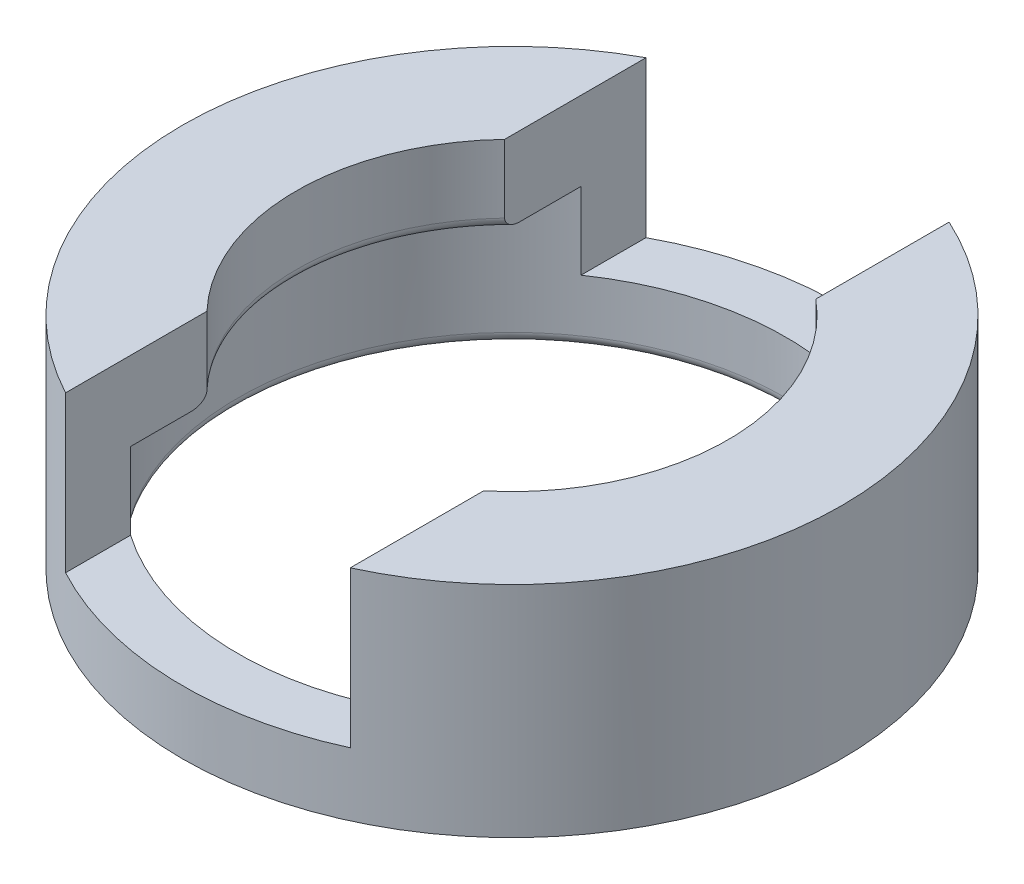
from build123d import *

# Parameters (mm, degrees)
SKETCH1_R               = 30.55
BOSS_EXTRUDE1_DEPTH     = 20.32
SKETCH2_R               = 25.404
CUT_EXTRUDE1_DEPTH      = 13
SKETCH3_R               = 20
CUT_EXTRUDE2_DEPTH      = 21.32
FILLET1_R               = 1
FILLET2_R               = 1
SKETCH4_W               = 27.244453354
SKETCH4_H               = 24.319072788
CUT_EXTRUDE3_DEPTH      = 31.55
CUT_EXTRUDE3_DEPTH_BACK = 31.55


with BuildPart() as part:
    # Sketch1 → Boss-Extrude1 (new body)
    with BuildSketch(Plane(origin=(0, 0, 0), x_dir=(1, 0, 0), z_dir=(0, 1, 0))):
        Circle(SKETCH1_R)
    extrude(amount=BOSS_EXTRUDE1_DEPTH)

    # Sketch2 → Cut-Extrude1 (cut)
    with BuildSketch(Plane.XZ):
        Circle(SKETCH2_R)
    extrude(amount=-CUT_EXTRUDE1_DEPTH, mode=Mode.SUBTRACT)

    # Sketch3 → Cut-Extrude2 (cut, through all)
    with BuildSketch(Plane(origin=(0, 20.32, 0), x_dir=(1, 0, 0), z_dir=(0, 1, 0))):
        Circle(SKETCH3_R)
    extrude(amount=-CUT_EXTRUDE2_DEPTH, mode=Mode.SUBTRACT)

    # Fillet1
    fillet1_edges = [part.edges().sort_by_distance(p)[0] for p in [
        (-25.404, 0, 0),
    ]]
    fillet(fillet1_edges, radius=FILLET1_R)

    # Fillet2
    fillet2_edges = [part.edges().sort_by_distance(p)[0] for p in [
        (-20, 13, 0),
    ]]
    fillet(fillet2_edges, radius=FILLET2_R)

    # Sketch4 → Cut-Extrude3 (cut, two sides)
    with BuildSketch(Plane.XY) as cut_extrude3_sk:
        with Locations((-0.856929661, 18.03488809)):
            Rectangle(SKETCH4_W, SKETCH4_H)
    extrude(amount=CUT_EXTRUDE3_DEPTH, mode=Mode.SUBTRACT)
    extrude(cut_extrude3_sk.sketch, amount=-CUT_EXTRUDE3_DEPTH_BACK, mode=Mode.SUBTRACT)


solid = part.part
